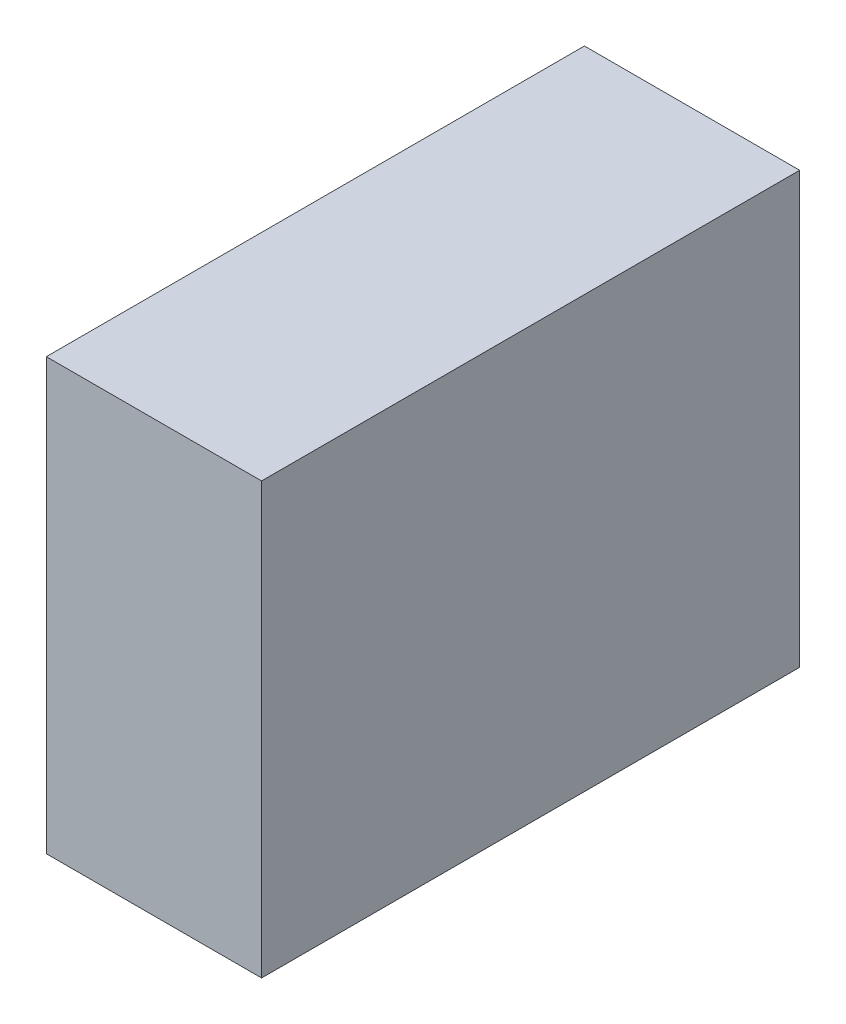
from build123d import *

# Parameters (mm, degrees)
SKETCH1_W           = 500
SKETCH1_H           = 400
BOSS_EXTRUDE1_DEPTH = 200


with BuildPart() as part:
    # Sketch1 → Boss-Extrude1 (new body)
    with BuildSketch(Plane(origin=(0, 0, 0), x_dir=(0, 0, -1), z_dir=(1, 0, 0))):
        Rectangle(SKETCH1_W, SKETCH1_H)
    extrude(amount=BOSS_EXTRUDE1_DEPTH)


solid = part.part
